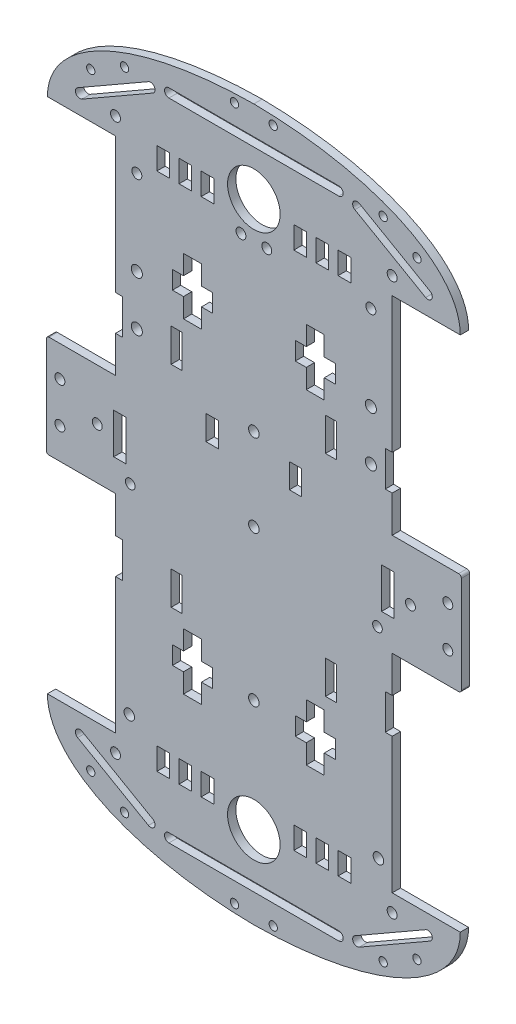
from build123d import *

# Parameters (mm, degrees)
SKETCH1_R           = 9.5
SKETCH1_R_2         = 2
SKETCH1_R_3         = 1.8
SKETCH1_R_4         = 1.5
SKETCH1_R_5         = 1.9
SKETCH1_R_6         = 1.75
SKETCH1_W           = 4.6
SKETCH1_H           = 8
SKETCH1_W_2         = 4.5
SKETCH1_H_2         = 8.864124738
SKETCH1_W_3         = 4
SKETCH1_H_3         = 12
SKETCH1_H_4         = 14.6
BOSS_EXTRUDE1_DEPTH = 3


with BuildPart() as part:
    # Sketch1 → Boss-Extrude1 (new body)
    with BuildSketch(Plane.XY.offset(3)):
        with BuildLine():
            Line((-139.654437838, 44.446894439), (-137.154437838, 44.446894439))
            Line((-137.154437838, 44.446894439), (-137.154437838, 93.462974016))
            Line((-137.154437838, 93.462974016), (-112.5426188, 93.462974016))
            add(Edge.make_bspline(
                [(-112.5426188, 93.462974016), (-112.577572475, 127.676128017), (-187.154437838, 128.5)],
                knots=[3.094561973, 3.094561973, 3.094561973, 4.452621226, 4.452621226, 4.452621226], degree=2, weights=[1, 0.778182517, 1]))
            add(Edge.make_bspline(
                [(-187.154437838, 128.5), (-261.7313032, 127.676128017), (-261.766256876, 93.462974016)],
                knots=[4.972156735, 4.972156735, 4.972156735, 6.330215988, 6.330215988, 6.330215988], degree=2, weights=[1, 0.778182517, 1]))
            Line((-261.766256876, 93.462974016), (-237.154437838, 93.462974016))
            Line((-237.154437838, 93.462974016), (-237.154437838, 44.446894439))
            Line((-237.154437838, 44.446894439), (-234.654437838, 44.446894439))
            Line((-234.654437838, 44.446894439), (-234.654437838, 31.678967302))
            Line((-234.654437838, 31.678967302), (-237.154437838, 31.678967302))
            Line((-237.154437838, 31.678967302), (-237.154437838, 18.462974016))
            Line((-237.154437838, 18.462974016), (-261.154437838, 18.462974016))
            ThreePointArc((-261.154437838, 18.462974016), (-261.861544619, 18.170080797), (-262.154437838, 17.462974016))
            Line((-262.154437838, 17.462974016), (-262.154437838, -17.462974016))
            ThreePointArc((-262.154437838, -17.462974016), (-261.861544619, -18.170080797), (-261.154437838, -18.462974016))
            Line((-261.154437838, -18.462974016), (-237.154437838, -18.462974016))
            Line((-237.154437838, -18.462974016), (-237.154437838, -31.678967302))
            Line((-237.154437838, -31.678967302), (-234.654437838, -31.678967302))
            Line((-234.654437838, -31.678967302), (-234.654437838, -44.446894439))
            Line((-234.654437838, -44.446894439), (-237.154437838, -44.446894439))
            Line((-237.154437838, -44.446894439), (-237.154437838, -93.462974016))
            Line((-237.154437838, -93.462974016), (-261.766256876, -93.462974016))
            add(Edge.make_bspline(
                [(-261.766256876, -93.462974016), (-261.7313032, -127.676128017), (-187.154437838, -128.5)],
                knots=[6.236154627, 6.236154627, 6.236154627, 7.59421388, 7.59421388, 7.59421388], degree=2, weights=[1, 0.778182517, 1]))
            add(Edge.make_bspline(
                [(-187.154437838, -128.5), (-112.577572475, -127.676128017), (-112.5426188, -93.462974016)],
                knots=[4.972156735, 4.972156735, 4.972156735, 6.330215988, 6.330215988, 6.330215988], degree=2, weights=[1, 0.778182517, 1]))
            Line((-112.5426188, -93.462974016), (-137.154437838, -93.462974016))
            Line((-137.154437838, -93.462974016), (-137.154437838, -44.446894439))
            Line((-137.154437838, -44.446894439), (-139.654437838, -44.446894439))
            Line((-139.654437838, -44.446894439), (-139.654437838, -31.678967302))
            Line((-139.654437838, -31.678967302), (-137.154437838, -31.678967302))
            Line((-137.154437838, -31.678967302), (-137.154437838, -18.462974016))
            Line((-137.154437838, -18.462974016), (-113.154437838, -18.462974016))
            ThreePointArc((-113.154437838, -18.462974016), (-112.447331057, -18.170080797), (-112.154437838, -17.462974016))
            Line((-112.154437838, -17.462974016), (-112.154437838, 17.462974016))
            ThreePointArc((-112.154437838, 17.462974016), (-112.447331057, 18.170080797), (-113.154437838, 18.462974016))
            Line((-113.154437838, 18.462974016), (-137.154437838, 18.462974016))
            Line((-137.154437838, 18.462974016), (-137.154437838, 31.678967302))
            Line((-137.154437838, 31.678967302), (-139.654437838, 31.678967302))
            Line((-139.654437838, 31.678967302), (-139.654437838, 44.446894439))
        make_face()
        with Locations((-187.154437838, 98.687197748)):
            Circle(SKETCH1_R, mode=Mode.SUBTRACT)
        with Locations((-229.45133143, 36.917956561)):
            Circle(SKETCH1_R_2, mode=Mode.SUBTRACT)
        with Locations((-229.449352206, 54.917956561)):
            Circle(SKETCH1_R_2, mode=Mode.SUBTRACT)
        with Locations((-257.261062641, 7.3)):
            Circle(SKETCH1_R_3, mode=Mode.SUBTRACT)
        with Locations((-194.154437838, 125.317141839)):
            Circle(SKETCH1_R_4, mode=Mode.SUBTRACT)
        with Locations((-233.898236168, 116.665209424)):
            Circle(SKETCH1_R_4, mode=Mode.SUBTRACT)
        with Locations((-246.110634148, 109.819967605)):
            Circle(SKETCH1_R_4, mode=Mode.SUBTRACT)
        with Locations((-237.148818465, 99.725491141)):
            Circle(SKETCH1_R_3, mode=Mode.SUBTRACT)
        with Locations((-229.445977331, 85.610657286)):
            Circle(SKETCH1_R_3, mode=Mode.SUBTRACT)
        with Locations((-191.820502848, 85.606520105)):
            Circle(SKETCH1_R_3, mode=Mode.SUBTRACT)
        with Locations((-182.488372828, 85.606520105)):
            Circle(SKETCH1_R_3, mode=Mode.SUBTRACT)
        with Locations((-144.862898344, 85.610657286)):
            Circle(SKETCH1_R_3, mode=Mode.SUBTRACT)
        with Locations((-137.160057211, 99.725491141)):
            Circle(SKETCH1_R_3, mode=Mode.SUBTRACT)
        with Locations((-128.198241527, 109.819967605)):
            Circle(SKETCH1_R_4, mode=Mode.SUBTRACT)
        with Locations((-140.410639508, 116.665209424)):
            Circle(SKETCH1_R_4, mode=Mode.SUBTRACT)
        with Locations((-180.154437838, 125.317141839)):
            Circle(SKETCH1_R_4, mode=Mode.SUBTRACT)
        with Locations((-117.047813034, 7.3)):
            Circle(SKETCH1_R_3, mode=Mode.SUBTRACT)
        with Locations((-144.85952347, 54.917956561)):
            Circle(SKETCH1_R_2, mode=Mode.SUBTRACT)
        with Locations((-144.857544245, 36.917956561)):
            Circle(SKETCH1_R_2, mode=Mode.SUBTRACT)
        with Locations((-243.747860089, 0)):
            Circle(SKETCH1_R_3, mode=Mode.SUBTRACT)
        with Locations((-237.148818465, -99.725491141)):
            Circle(SKETCH1_R_3, mode=Mode.SUBTRACT)
        with Locations((-246.110634148, -109.819967605)):
            Circle(SKETCH1_R_4, mode=Mode.SUBTRACT)
        with Locations((-233.898236168, -116.665209424)):
            Circle(SKETCH1_R_4, mode=Mode.SUBTRACT)
        with Locations((-194.154437838, -125.317141839)):
            Circle(SKETCH1_R_4, mode=Mode.SUBTRACT)
        with Locations((-257.261062641, -7.3)):
            Circle(SKETCH1_R_3, mode=Mode.SUBTRACT)
        with Locations((-137.160057211, -99.725491141)):
            Circle(SKETCH1_R_3, mode=Mode.SUBTRACT)
        with Locations((-128.198241527, -109.819967605)):
            Circle(SKETCH1_R_4, mode=Mode.SUBTRACT)
        with Locations((-140.410639508, -116.665209424)):
            Circle(SKETCH1_R_4, mode=Mode.SUBTRACT)
        with Locations((-180.154437838, -125.317141839)):
            Circle(SKETCH1_R_4, mode=Mode.SUBTRACT)
        with Locations((-117.047813034, -7.3)):
            Circle(SKETCH1_R_3, mode=Mode.SUBTRACT)
        with Locations((-187.154437838, -98.687197748)):
            Circle(SKETCH1_R, mode=Mode.SUBTRACT)
        with Locations((-130.561015586, 0)):
            Circle(SKETCH1_R_3, mode=Mode.SUBTRACT)
        with Locations((-232.181386347, -85.144618245)):
            Circle(SKETCH1_R_5, mode=Mode.SUBTRACT)
        with Locations((-142.474241724, -12.788348158)):
            Circle(SKETCH1_R_6, mode=Mode.SUBTRACT)
        with Locations((-187.154437838, -3.869303663)):
            Circle(SKETCH1_R_5, mode=Mode.SUBTRACT)
        with Locations((-142.127489329, -85.144618245)):
            Circle(SKETCH1_R_5, mode=Mode.SUBTRACT)
        with Locations((-231.834633951, -12.788348158)):
            Circle(SKETCH1_R_6, mode=Mode.SUBTRACT)
        with Locations((-187.154437838, 25.949221825)):
            Circle(SKETCH1_R_5, mode=Mode.SUBTRACT)
        with Locations((-187.154437838, -58.184487035)):
            Circle(SKETCH1_R_5, mode=Mode.SUBTRACT)
        with Locations((-203.905019377, 93.96045009)):
            Rectangle(SKETCH1_W, SKETCH1_H, mode=Mode.SUBTRACT)
        with Locations((-211.905019377, 93.96045009)):
            Rectangle(SKETCH1_W, SKETCH1_H, mode=Mode.SUBTRACT)
        with Locations((-219.905019377, 93.96045009)):
            Rectangle(SKETCH1_W, SKETCH1_H, mode=Mode.SUBTRACT)
        Polygon((-212.596087231, 55.483420667), (-216.583359492, 55.483420667), (-216.583359492, 61.983420667), (-212.596087231, 61.983420667), (-212.596087231, 68.983420667), (-206.096087231, 68.983420667), (-206.096087231, 61.983420667), (-202.129152901, 61.983420667), (-202.129152901, 55.483420667), (-206.096087231, 55.483420667), (-206.096087231, 48.483420667), (-212.596087231, 48.483420667), align=None, mode=Mode.SUBTRACT)
        with Locations((-202.214831799, 18.534756411)):
            Rectangle(SKETCH1_W_2, SKETCH1_H_2, mode=Mode.SUBTRACT)
        with Locations((-215.050930671, 38.025125224)):
            Rectangle(SKETCH1_W_3, SKETCH1_H_3, mode=Mode.SUBTRACT)
        with BuildLine():
            Line((-250.843817198, 101.721515577), (-225.257179397, 116.407555374))
            ThreePointArc((-225.257179397, 116.407555374), (-223.073031341, 115.816372434), (-223.664214281, 113.632224378))
            Line((-223.664214281, 113.632224378), (-249.250852082, 98.946184581))
            ThreePointArc((-249.250852082, 98.946184581), (-251.435000138, 99.537367521), (-250.843817198, 101.721515577))
        make_face(mode=Mode.SUBTRACT)
        with BuildLine():
            Line((-125.058023594, 98.946184581), (-150.644661395, 113.632224378))
            ThreePointArc((-150.644661395, 113.632224378), (-151.235844335, 115.816372434), (-149.051696278, 116.407555374))
            Line((-149.051696278, 116.407555374), (-123.465058478, 101.721515577))
            ThreePointArc((-123.465058478, 101.721515577), (-122.873875538, 99.537367521), (-125.058023594, 98.946184581))
        make_face(mode=Mode.SUBTRACT)
        with Locations((-159.257945005, 38.025125224)):
            Rectangle(SKETCH1_W_3, SKETCH1_H_3, mode=Mode.SUBTRACT)
        with Locations((-172.094043876, 18.534756411)):
            Rectangle(SKETCH1_W_2, SKETCH1_H_2, mode=Mode.SUBTRACT)
        Polygon((-157.725516184, 55.483420667), (-161.712788445, 55.483420667), (-161.712788445, 48.483420667), (-168.212788445, 48.483420667), (-168.212788445, 55.483420667), (-172.179722775, 55.483420667), (-172.179722775, 61.983420667), (-168.212788445, 61.983420667), (-168.212788445, 68.983420667), (-161.712788445, 68.983420667), (-161.712788445, 61.983420667), (-157.725516184, 61.983420667), align=None, mode=Mode.SUBTRACT)
        with Locations((-154.403856298, 93.96045009)):
            Rectangle(SKETCH1_W, SKETCH1_H, mode=Mode.SUBTRACT)
        with Locations((-162.403856298, 93.96045009)):
            Rectangle(SKETCH1_W, SKETCH1_H, mode=Mode.SUBTRACT)
        with Locations((-170.403856298, 93.96045009)):
            Rectangle(SKETCH1_W, SKETCH1_H, mode=Mode.SUBTRACT)
        with BuildLine():
            Line((-217.853420634, 118.190228394), (-156.455455042, 118.190228394))
            ThreePointArc((-156.455455042, 118.190228394), (-154.855455042, 116.590228394), (-156.455455042, 114.990228394))
            Line((-156.455455042, 114.990228394), (-217.853420634, 114.990228394))
            ThreePointArc((-217.853420634, 114.990228394), (-219.453420634, 116.590228394), (-217.853420634, 118.190228394))
        make_face(mode=Mode.SUBTRACT)
        with BuildLine():
            Line((-249.250852082, -98.946184581), (-223.664214281, -113.632224378))
            ThreePointArc((-223.664214281, -113.632224378), (-223.073031341, -115.816372434), (-225.257179397, -116.407555374))
            Line((-225.257179397, -116.407555374), (-250.843817198, -101.721515577))
            ThreePointArc((-250.843817198, -101.721515577), (-251.435000138, -99.537367521), (-249.250852082, -98.946184581))
        make_face(mode=Mode.SUBTRACT)
        with Locations((-215.050930671, -38.025125224)):
            Rectangle(SKETCH1_W_3, SKETCH1_H_3, mode=Mode.SUBTRACT)
        Polygon((-216.583359492, -55.483420667), (-212.596087231, -55.483420667), (-212.596087231, -48.483420667), (-206.096087231, -48.483420667), (-206.096087231, -55.483420667), (-202.129152901, -55.483420667), (-202.129152901, -61.983420667), (-206.096087231, -61.983420667), (-206.096087231, -68.983420667), (-212.596087231, -68.983420667), (-212.596087231, -61.983420667), (-216.583359492, -61.983420667), align=None, mode=Mode.SUBTRACT)
        with Locations((-219.905019377, -93.96045009)):
            Rectangle(SKETCH1_W, SKETCH1_H, mode=Mode.SUBTRACT)
        with Locations((-211.905019377, -93.96045009)):
            Rectangle(SKETCH1_W, SKETCH1_H, mode=Mode.SUBTRACT)
        with Locations((-203.905019377, -93.96045009)):
            Rectangle(SKETCH1_W, SKETCH1_H, mode=Mode.SUBTRACT)
        with Locations((-235.54600027, 0)):
            Rectangle(SKETCH1_W_2, SKETCH1_H_4, mode=Mode.SUBTRACT)
        with Locations((-138.762875406, 0)):
            Rectangle(SKETCH1_W_2, SKETCH1_H_4, mode=Mode.SUBTRACT)
        with BuildLine():
            Line((-123.465058478, -101.721515577), (-149.051696278, -116.407555374))
            ThreePointArc((-149.051696278, -116.407555374), (-151.235844335, -115.816372434), (-150.644661395, -113.632224378))
            Line((-150.644661395, -113.632224378), (-125.058023594, -98.946184581))
            ThreePointArc((-125.058023594, -98.946184581), (-122.873875538, -99.537367521), (-123.465058478, -101.721515577))
        make_face(mode=Mode.SUBTRACT)
        with Locations((-159.257945005, -38.025125224)):
            Rectangle(SKETCH1_W_3, SKETCH1_H_3, mode=Mode.SUBTRACT)
        Polygon((-161.712788445, -55.483420667), (-157.725516184, -55.483420667), (-157.725516184, -61.983420667), (-161.712788445, -61.983420667), (-161.712788445, -68.983420667), (-168.212788445, -68.983420667), (-168.212788445, -61.983420667), (-172.179722775, -61.983420667), (-172.179722775, -55.483420667), (-168.212788445, -55.483420667), (-168.212788445, -48.483420667), (-161.712788445, -48.483420667), align=None, mode=Mode.SUBTRACT)
        with Locations((-154.403856298, -93.96045009)):
            Rectangle(SKETCH1_W, SKETCH1_H, mode=Mode.SUBTRACT)
        with Locations((-162.403856298, -93.96045009)):
            Rectangle(SKETCH1_W, SKETCH1_H, mode=Mode.SUBTRACT)
        with Locations((-170.403856298, -93.96045009)):
            Rectangle(SKETCH1_W, SKETCH1_H, mode=Mode.SUBTRACT)
        with BuildLine():
            Line((-156.455455042, -118.190228394), (-217.853420634, -118.190228394))
            ThreePointArc((-217.853420634, -118.190228394), (-219.453420634, -116.590228394), (-217.853420634, -114.990228394))
            Line((-217.853420634, -114.990228394), (-156.455455042, -114.990228394))
            ThreePointArc((-156.455455042, -114.990228394), (-154.855455042, -116.590228394), (-156.455455042, -118.190228394))
        make_face(mode=Mode.SUBTRACT)
    extrude(amount=-BOSS_EXTRUDE1_DEPTH)


solid = part.part
